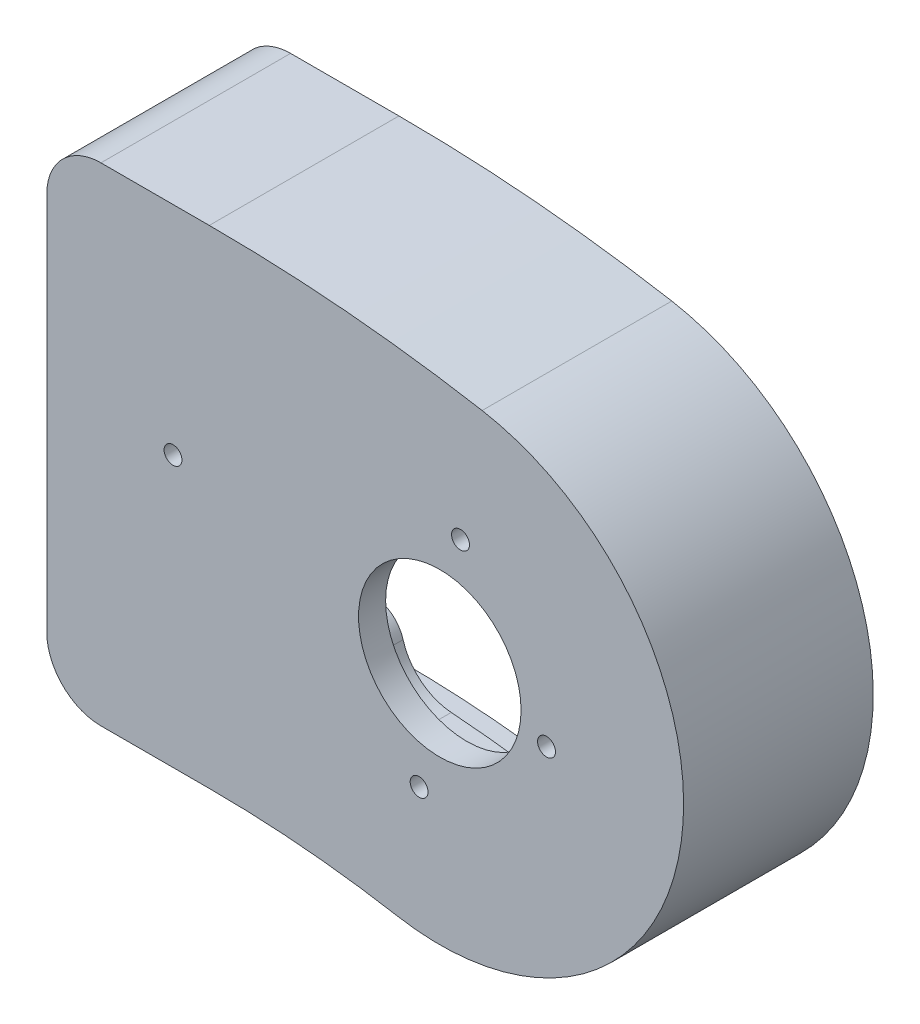
from build123d import *

# Parameters (mm, degrees)
EXTRUDE_1_DEPTH        = 35
CUT_EXTRUDE_1_DEPTH    = 30
SKETCH_3_R             = 20
SKETCH_3_R_2           = 2.25
CUT_EXTRUDE_2_DEPTH    = 5
CUT_EXTRUDE_3_REACH    = 37
SKETCH_4_R             = 15
CUT_EXTRUDE_5_DEPTH    = 5
SKETCH_8_R             = 6
EXTRUDE_2_DEPTH        = 25
FILLET_1_R             = 10
HOLE_WIZARD_M4_2_D     = 3.3
HOLE_WIZARD_M4_2_DEPTH = 11.5
HOLE_WIZARD_M4_2_TIP   = 0.991420021
HOLE_WIZARD_M4_3_D     = 3.3
HOLE_WIZARD_M4_3_DEPTH = 11.5
HOLE_WIZARD_M4_3_TIP   = 0.991420021


with BuildPart() as part:
    # 스케치1 → 보스-돌출1 (new body)
    with BuildSketch(Plane.XY):
        with BuildLine():
            Line((-5, 45), (15, 45))
            ThreePointArc((15, 45), (40.275165397, 43.896462447), (65.357971523, 40.594248374))
            ThreePointArc((65.357971523, 40.594248374), (101.860152414, -11.536268507), (49.729635533, -48.038449398))
            ThreePointArc((49.729635533, -48.038449398), (32.43114855, -45.761060382), (15, -45))
            Line((15, -45), (-5, -45))
            ThreePointArc((-5, -45), (-12.071067812, -42.071067812), (-15, -35))
            Line((-15, -35), (-15, 35))
            ThreePointArc((-15, 35), (-12.071067812, 42.071067812), (-5, 45))
        make_face()
    extrude(amount=EXTRUDE_1_DEPTH)

    # 스케치2 → 컷-돌출1 (cut)
    with BuildSketch(Plane(origin=(0, 0, 0), x_dir=(-1, 0, 0), z_dir=(0, 0, -1))):
        with BuildLine():
            Line((-15, -40), (5, -40))
            ThreePointArc((5, -40), (8.535533906, -38.535533906), (10, -35))
            Line((10, -35), (10, 35))
            ThreePointArc((10, 35), (8.535533906, 38.535533906), (5, 40))
            Line((5, 40), (-15, 40))
            ThreePointArc((-15, 40), (-39.839386683, 38.915488956), (-64.489730635, 35.670209608))
            ThreePointArc((-64.489730635, 35.670209608), (-96.936113649, -10.668027619), (-50.597876422, -43.114410632))
            ThreePointArc((-50.597876422, -43.114410632), (-32.866927263, -40.780086891), (-15, -40))
        make_face()
    extrude(amount=-CUT_EXTRUDE_1_DEPTH, mode=Mode.SUBTRACT)

    # 스케치3 → 컷-돌출2 (cut)
    with BuildSketch(Plane.ZY.offset(15)):
        Circle(SKETCH_3_R)
        with Locations((12.5, 21.650635095)):
            Circle(SKETCH_3_R_2)
        with Locations((25, 0)):
            Circle(SKETCH_3_R_2)
        with Locations((12.5, -21.650635095)):
            Circle(SKETCH_3_R_2)
    extrude(amount=-CUT_EXTRUDE_2_DEPTH, mode=Mode.SUBTRACT)

    # 스케치4 → 컷-돌출3 (cut, up to next)
    with BuildSketch(Plane.XY.offset(35), mode=Mode.PRIVATE) as cut_extrude_3_sk1:
        with Locations((57.543803528, -3.722100512)):
            Circle(SKETCH_4_R)
    cut_extrude_3_tool1 = extrude(cut_extrude_3_sk1.sketch, amount=-CUT_EXTRUDE_3_REACH, mode=Mode.PRIVATE) & part.part
    add(cut_extrude_3_tool1.solids().sort_by_distance((57.543804, -3.722101, 35))[0], mode=Mode.SUBTRACT)

    # 스케치6 → 컷-돌출5 (cut)
    with BuildSketch(Plane(origin=(0, 0, 0), x_dir=(-1, 0, 0), z_dir=(0, 0, -1))):
        with BuildLine():
            Line((10, 21.02711573), (10, 19.021261947))
            Line((10, 19.021261947), (12, 19.021261947))
            Line((12, 19.021261947), (12, 21.02711573))
            Line((12, 21.02711573), (12, 35))
            ThreePointArc((12, 35), (9.949747468, 39.949747468), (5, 42))
            Line((5, 42), (-15, 42))
            ThreePointArc((-15, 42), (-40.013698169, 40.907878352), (-64.83702699, 37.639825115))
            ThreePointArc((-64.83702699, 37.639825115), (-98.905729155, -11.015323974), (-50.250580066, -45.084026139))
            ThreePointArc((-50.250580066, -45.084026139), (-32.692615778, -42.772476287), (-15, -42))
            Line((-15, -42), (5, -42))
            ThreePointArc((5, -42), (9.949747468, -39.949747468), (12, -35))
            Line((12, -35), (12, -19.081512787))
            Line((12, -19.081512787), (10, -19.081512787))
            Line((10, -19.081512787), (10, -35))
            ThreePointArc((10, -35), (8.535533906, -38.535533906), (5, -40))
            Line((5, -40), (-15, -40))
            ThreePointArc((-15, -40), (-32.866927263, -40.780086891), (-50.597876422, -43.114410632))
            ThreePointArc((-50.597876422, -43.114410632), (-96.936113649, -10.668027619), (-64.489730635, 35.670209608))
            ThreePointArc((-64.489730635, 35.670209608), (-39.839386683, 38.915488956), (-15, 40))
            Line((-15, 40), (5, 40))
            ThreePointArc((5, 40), (8.535533906, 38.535533906), (10, 35))
            Line((10, 35), (10, 21.02711573))
        make_face()
    extrude(amount=-CUT_EXTRUDE_5_DEPTH, mode=Mode.SUBTRACT)

    # 스케치8 → 보스-돌출2 (add)
    with BuildSketch(Plane(origin=(0, 0, 30), x_dir=(-1, 0, 0), z_dir=(0, 0, -1))):
        with Locations((-15, 35)):
            Circle(SKETCH_8_R)
        with Locations((-15, -35)):
            Circle(SKETCH_8_R)
    extrude(amount=EXTRUDE_2_DEPTH)

    # 필렛1
    fillet_1_edges = [part.edges().sort_by_distance(p)[0] for p in [
        (18.346048824, 39.980357143, 17.5),
        (11.68337521, 40, 17.5),
        (18.276798635, -40.026190476, 17.5),
        (11.68337521, -40, 17.5),
    ]]
    fillet(fillet_1_edges, radius=FILLET_1_R)

    # M4 나사 구멍2
    with Locations(Plane(origin=(0, 0, 30), x_dir=(-1, 0, 0), z_dir=(0, 0, -1))):
        with Locations((-61.364063437, 17.943670054), (-77.239958589, -7.195064065), (-53.72354362, -25.387871078), (-8.303415878, 4.960308371)):
            Hole(HOLE_WIZARD_M4_2_D / 2, depth=HOLE_WIZARD_M4_2_DEPTH)
            with Locations((0, 0, -(HOLE_WIZARD_M4_2_DEPTH + HOLE_WIZARD_M4_2_TIP / 2))):  # 118° drill point
                Cone(0, HOLE_WIZARD_M4_2_D / 2, HOLE_WIZARD_M4_2_TIP, mode=Mode.SUBTRACT)

    # M4 나사 구멍3
    with Locations(Plane(origin=(0, 0, 5), x_dir=(-1, 0, 0), z_dir=(0, 0, -1))):
        with Locations((-15, 35), (-15, -35)):
            Hole(HOLE_WIZARD_M4_3_D / 2, depth=HOLE_WIZARD_M4_3_DEPTH)
            with Locations((0, 0, -(HOLE_WIZARD_M4_3_DEPTH + HOLE_WIZARD_M4_3_TIP / 2))):  # 118° drill point
                Cone(0, HOLE_WIZARD_M4_3_D / 2, HOLE_WIZARD_M4_3_TIP, mode=Mode.SUBTRACT)


solid = part.part
